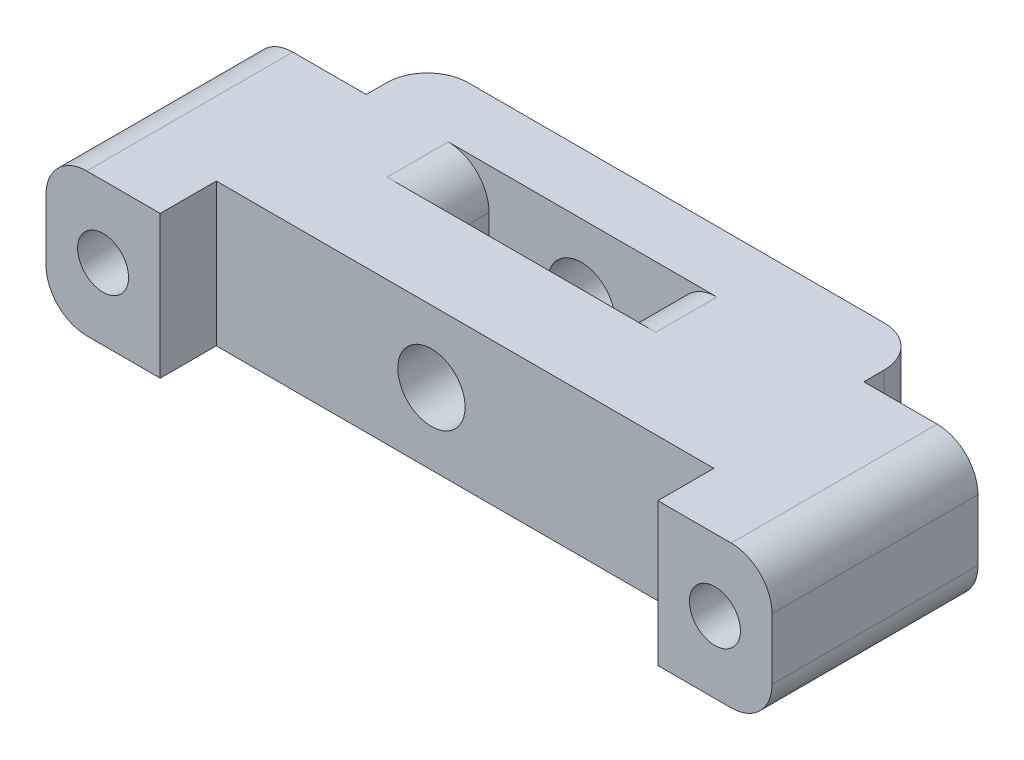
from build123d import *

# Parameters (mm, degrees)
SKETCH1_W           = 9.175
SKETCH1_H           = 3
BOSS_EXTRUDE1_DEPTH = 3.5
SKETCH2_R           = 1.25
SKETCH2_R_2         = 1.65
CUT_EXTRUDE1_DEPTH  = 14.1
SKETCH3_W           = 5.6
SKETCH3_H           = 7
CUT_EXTRUDE2_DEPTH  = 3
FILLET1_R           = 2


with BuildPart() as part:
    # Sketch1 → Boss-Extrude1 (new body, symmetric)
    with BuildSketch(Plane(origin=(0, 0, 0), x_dir=(1, 0, 0), z_dir=(0, 1, 0))):
        Polygon((-17.8, 10.35), (17.8, 10.35), (17.8, -2.75), (12.2, -2.75), (12.2, 0), (-12.2, 0), (-12.2, -2.75), (-17.8, -2.75), align=None)
        with Locations((-1.5875, 5.85)):
            Rectangle(SKETCH1_W, SKETCH1_H, mode=Mode.SUBTRACT)
    extrude(amount=BOSS_EXTRUDE1_DEPTH, both=True)

    # Sketch2 → Cut-Extrude1 (cut, through all)
    with BuildSketch(Plane(origin=(0, 0, -10.35), x_dir=(-1, 0, 0), z_dir=(0, 0, -1))):
        with Locations((15, 0)):
            Circle(SKETCH2_R)
        with Locations((1.65, 0)):
            Circle(SKETCH2_R_2)
        with Locations((-15, 0)):
            Circle(SKETCH2_R)
    extrude(amount=-CUT_EXTRUDE1_DEPTH, mode=Mode.SUBTRACT)

    # Sketch3 → Cut-Extrude2 (cut)
    with BuildSketch(Plane(origin=(0, 0, -10.35), x_dir=(-1, 0, 0), z_dir=(0, 0, -1))):
        with Locations((15, 0)):
            Rectangle(SKETCH3_W, SKETCH3_H)
        with Locations((-15, 0)):
            Rectangle(SKETCH3_W, SKETCH3_H)
    extrude(amount=-CUT_EXTRUDE2_DEPTH, mode=Mode.SUBTRACT)

    # Fillet1
    fillet1_edges = [part.edges().sort_by_distance(p)[0] for p in [
        (17.8, -3.5, -2.3),
        (-6.175, -3.5, -5.85),
        (3, -3.5, -5.85),
        (-6.175, 3.5, -5.85),
        (3, 3.5, -5.85),
        (-17.8, -3.5, -2.3),
        (-17.8, 3.5, -2.3),
        (-12.2, 0, -10.35),
        (17.8, 3.5, -2.3),
        (12.2, 0, -10.35),
    ]]
    fillet(fillet1_edges, radius=FILLET1_R)


solid = part.part
